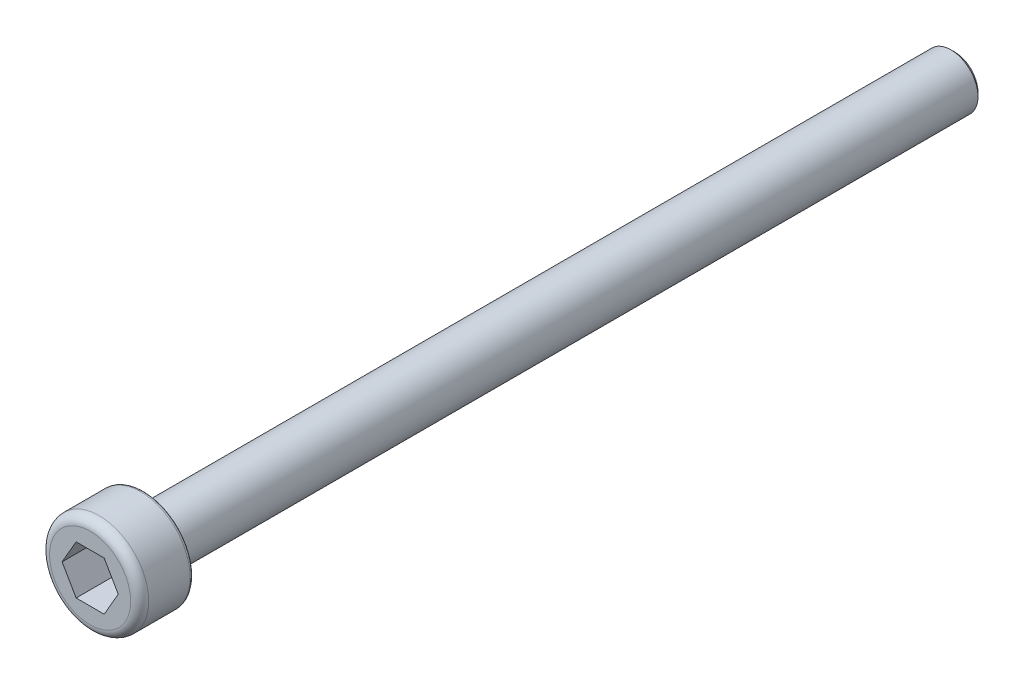
from build123d import *

# Parameters (mm, degrees)
SKETCH_1_R          = 2.75
EXTRUDE_1_DEPTH     = 3
FILLET_1_R          = 0.5
CUT_EXTRUDE_1_DEPTH = 2
SKETCH_3_R          = 1.5
EXTRUDE_2_DEPTH     = 45
CHAMFER_1_SIZE      = 0.2
FILLET_2_R          = 0.2


with BuildPart() as part:
    # 草图1 → 凸台-拉伸1 (new body)
    with BuildSketch(Plane.XY):
        Circle(SKETCH_1_R)
    extrude(amount=EXTRUDE_1_DEPTH)

    # 圆角1
    fillet_1_edges = [part.edges().sort_by_distance(p)[0] for p in [
        (-2.75, 0, 3),
    ]]
    fillet(fillet_1_edges, radius=FILLET_1_R)

    # 草图2 → 切除-拉伸1 (cut)
    with BuildSketch(Plane.XY.offset(3)):
        Polygon((1.558845727, 0), (0.779422863, 1.35), (-0.779422863, 1.35), (-1.558845727, 0), (-0.779422863, -1.35), (0.779422863, -1.35), align=None)
    extrude(amount=-CUT_EXTRUDE_1_DEPTH, mode=Mode.SUBTRACT)

    # 草图3 → 凸台-拉伸2 (add)
    with BuildSketch(Plane(origin=(0, 0, 0), x_dir=(-1, 0, 0), z_dir=(0, 0, -1))):
        Circle(SKETCH_3_R)
    extrude(amount=EXTRUDE_2_DEPTH)

    # 倒角1
    chamfer_1_edges = [part.edges().sort_by_distance(p)[0] for p in [
        (1.5, 0, -45),
    ]]
    chamfer(chamfer_1_edges, length=CHAMFER_1_SIZE)

    # 圆角2
    fillet_2_edges = [part.edges().sort_by_distance(p)[0] for p in [
        (-2.75, 0, 0),
    ]]
    fillet(fillet_2_edges, radius=FILLET_2_R)


solid = part.part
